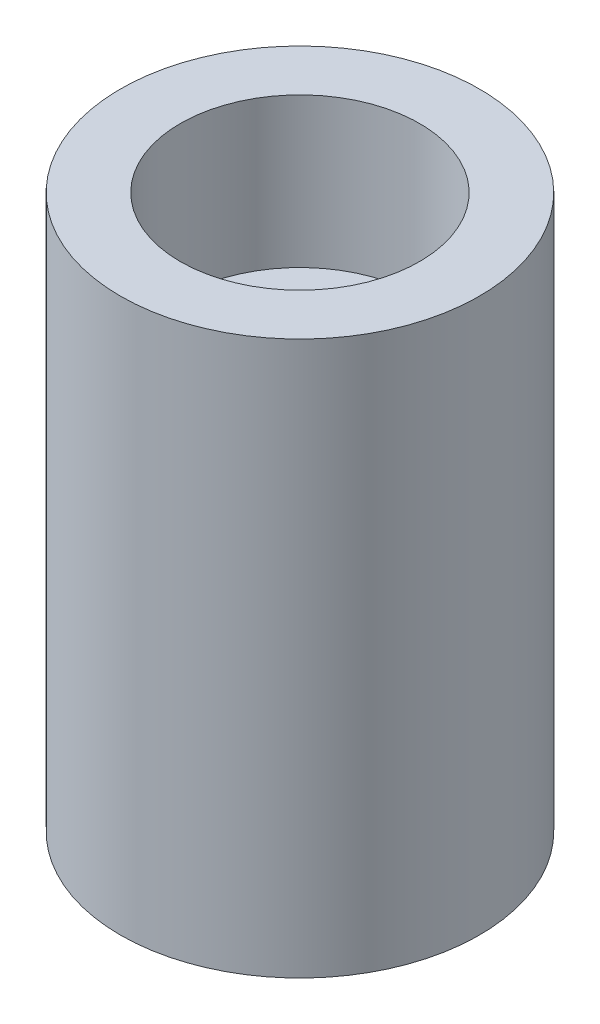
from build123d import *

# Parameters (mm, degrees)
SKETCH2_R           = 6
BOSS_EXTRUDE2_DEPTH = 18.5
SKETCH3_R           = 4
CUT_EXTRUDE1_DEPTH  = 16.5
CUT_EXTRUDE2_REACH  = 4
SKETCH4_R           = 1.5
SKETCH5_R           = 4
SKETCH5_R_2         = 3
BOSS_EXTRUDE3_DEPTH = 11.5


with BuildPart() as part:
    # Sketch2 → Boss-Extrude2 (new body)
    with BuildSketch(Plane(origin=(0, 0, 0), x_dir=(1, 0, 0), z_dir=(0, 1, 0))):
        Circle(SKETCH2_R)
    extrude(amount=BOSS_EXTRUDE2_DEPTH)

    # Sketch3 → Cut-Extrude1 (cut)
    with BuildSketch(Plane(origin=(0, 18.5, 0), x_dir=(1, 0, 0), z_dir=(0, 1, 0))):
        Circle(SKETCH3_R)
    extrude(amount=-CUT_EXTRUDE1_DEPTH, mode=Mode.SUBTRACT)

    # Sketch4 → Cut-Extrude2 (cut, up to next)
    with BuildSketch(Plane(origin=(0, 2, 0), x_dir=(1, 0, 0), z_dir=(0, 1, 0)), mode=Mode.PRIVATE) as cut_extrude2_sk1:
        Circle(SKETCH4_R)
    cut_extrude2_tool1 = extrude(cut_extrude2_sk1.sketch, amount=-CUT_EXTRUDE2_REACH, mode=Mode.PRIVATE) & part.part
    add(cut_extrude2_tool1.solids().sort_by_distance((0, 2, 0))[0], mode=Mode.SUBTRACT)

    # Sketch5 → Boss-Extrude3 (add)
    with BuildSketch(Plane(origin=(0, 2, 0), x_dir=(1, 0, 0), z_dir=(0, 1, 0))):
        Circle(SKETCH5_R)
        Circle(SKETCH5_R_2, mode=Mode.SUBTRACT)
    extrude(amount=BOSS_EXTRUDE3_DEPTH)


solid = part.part
